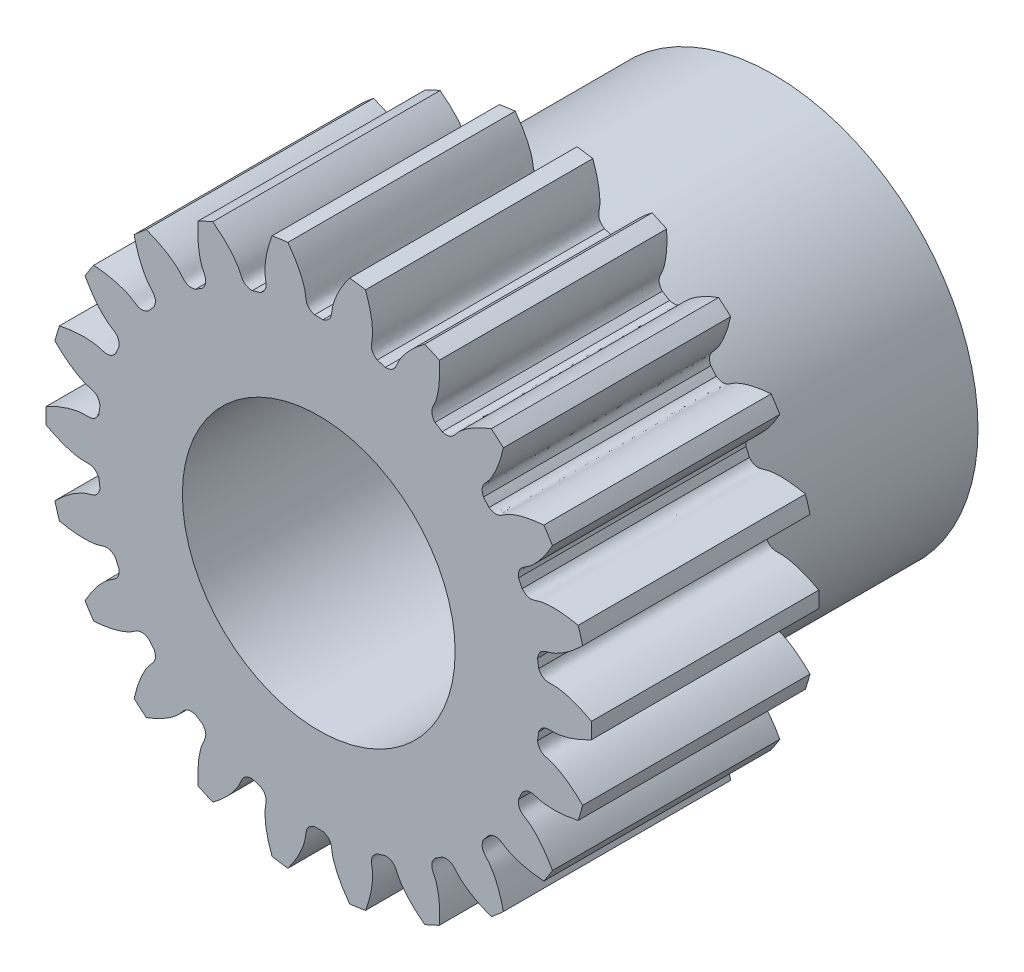
from build123d import *

# Parameters (mm, degrees)
SKETCH_1_R               = 12
EXTRUDE_1_DEPTH          = 10
CUT_EXTRUDE_1_DEPTH      = 20.697715604
PATTERN_CIRCULAR_1_COUNT = 22
SKETCH_4_R               = 9
EXTRUDE_2_DEPTH          = 10
SKETCH_5_R               = 6
CUT_EXTRUDE_2_DEPTH      = 27.194559786


with BuildPart() as part:
    # 草图1 → 凸台-拉伸1 (new body)
    with BuildSketch(Plane.XY):
        Circle(SKETCH_1_R)
    extrude(amount=EXTRUDE_1_DEPTH)

    # 草图2 → 切除-拉伸1 (cut, through all)
    with BuildSketch(Plane.XY):
        with BuildLine():
            ThreePointArc((0.185665431, 9.748232063), (0, 9.75), (-0.185665431, 9.748232063))
            add(Edge.make_bspline(
                [(-0.185665431, 9.748232063), (-0.588158706, 9.876186429), (-0.548347264, 10.151774696), (-0.599584047, 10.42157039), (-0.60596118, 10.451918903), (-0.613876897, 10.486162213), (-0.623483721, 10.524250431), (-0.634939934, 10.566127653), (-0.648399943, 10.611733662), (-0.664017171, 10.661003439), (-0.681942991, 10.713867378), (-0.70232689, 10.77025128), (-0.72531626, 10.830076418), (-0.751056303, 10.893259589), (-0.779689902, 10.959713172), (-0.811357505, 11.029345185), (-0.846197011, 11.10205935), (-0.884343649, 11.177755162), (-0.925929868, 11.25632795), (-0.971085225, 11.337668957), (-1.019936271, 11.421665408), (-1.072606448, 11.508200591), (-1.129215979, 11.597153935), (-1.189881763, 11.688401095), (-1.254717274, 11.781814033), (-1.323832459, 11.877261111), (-1.397333644, 11.974607178), (-1.475323431, 12.073713662), (-1.557900608, 12.174438668), (-1.64516006, 12.276637076), (-1.737192673, 12.380160638), (-1.834085256, 12.484858081), (-1.935920447, 12.590575215), (-2.042776642, 12.697155033), (-2.154727905, 12.804437827), (-2.271843904, 12.912261294), (-2.394189822, 13.020460649), (-2.521826308, 13.128868741), (-2.654809363, 13.237316171), (-2.841488127, 13.383435539), (-2.986445715, 13.489968103), (-3.085558798, 13.559868128)],
                knots=[0, 0, 0, 0, 0.157021319, 0.162530984, 0.168888289, 0.176093235, 0.184145822, 0.19304605, 0.202793918, 0.213389427, 0.224832576, 0.237123367, 0.250261798, 0.264247869, 0.279081582, 0.294762935, 0.311291928, 0.328668563, 0.346892838, 0.365964754, 0.38588431, 0.406651508, 0.428266346, 0.450728824, 0.474038944, 0.498196704, 0.523202104, 0.549055146, 0.575755828, 0.603304151, 0.631700114, 0.660943719, 0.691034964, 0.721973849, 0.753760376, 0.786394543, 0.819876351, 0.854205799, 0.889382888, 0.925407618, 1, 1, 1, 1], degree=3))
            ThreePointArc((-3.085558798, 13.559868128), (0, 13.906498364), (3.085558798, 13.559868128))
            add(Edge.make_bspline(
                [(0.185665431, 9.748232063), (0.588158706, 9.876186429), (0.548347264, 10.151774696), (0.599584047, 10.42157039), (0.60596118, 10.451918903), (0.613876897, 10.486162213), (0.623483721, 10.524250431), (0.634939934, 10.566127653), (0.648399943, 10.611733662), (0.664017171, 10.661003439), (0.681942991, 10.713867378), (0.70232689, 10.77025128), (0.72531626, 10.830076418), (0.751056303, 10.893259589), (0.779689902, 10.959713172), (0.811357505, 11.029345185), (0.846197011, 11.10205935), (0.884343649, 11.177755162), (0.925929868, 11.25632795), (0.971085225, 11.337668957), (1.019936271, 11.421665408), (1.072606448, 11.508200591), (1.129215979, 11.597153935), (1.189881763, 11.688401095), (1.254717274, 11.781814033), (1.323832459, 11.877261111), (1.397333644, 11.974607178), (1.475323431, 12.073713662), (1.557900608, 12.174438668), (1.64516006, 12.276637076), (1.737192673, 12.380160638), (1.834085256, 12.484858081), (1.935920447, 12.590575215), (2.042776642, 12.697155033), (2.154727905, 12.804437827), (2.271843904, 12.912261294), (2.394189822, 13.020460649), (2.521826308, 13.128868741), (2.654809363, 13.237316171), (2.841488127, 13.383435539), (2.986445715, 13.489968103), (3.085558798, 13.559868128)],
                knots=[0, 0, 0, 0, 0.157021319, 0.162530984, 0.168888289, 0.176093235, 0.184145822, 0.19304605, 0.202793918, 0.213389427, 0.224832576, 0.237123367, 0.250261798, 0.264247869, 0.279081582, 0.294762935, 0.311291928, 0.328668563, 0.346892838, 0.365964754, 0.38588431, 0.406651508, 0.428266346, 0.450728824, 0.474038944, 0.498196704, 0.523202104, 0.549055146, 0.575755828, 0.603304151, 0.631700114, 0.660943719, 0.691034964, 0.721973849, 0.753760376, 0.786394543, 0.819876351, 0.854205799, 0.889382888, 0.925407618, 1, 1, 1, 1], degree=3))
        make_face()
    cut_extrude_1 = extrude(amount=CUT_EXTRUDE_1_DEPTH, mode=Mode.SUBTRACT)

    # 阵列(圆周)1: 切除-拉伸1 ×22 about axis
    pattern_circular_1_axis = Axis((0, 0, -0.5), (0, 0, 1))
    for i in range(1, PATTERN_CIRCULAR_1_COUNT):
        add(cut_extrude_1.rotate(pattern_circular_1_axis, i * 360 / PATTERN_CIRCULAR_1_COUNT), mode=Mode.SUBTRACT)

    # 草图4 → 凸台-拉伸2 (add)
    with BuildSketch(Plane.XY):
        Circle(SKETCH_4_R)
    extrude(amount=-EXTRUDE_2_DEPTH)

    # 草图5 → 切除-拉伸2 (cut, through all)
    with BuildSketch(Plane(origin=(0, 0, -10), x_dir=(-1, 0, 0), z_dir=(0, 0, -1))):
        Circle(SKETCH_5_R)
    extrude(amount=-CUT_EXTRUDE_2_DEPTH, mode=Mode.SUBTRACT)


solid = part.part
